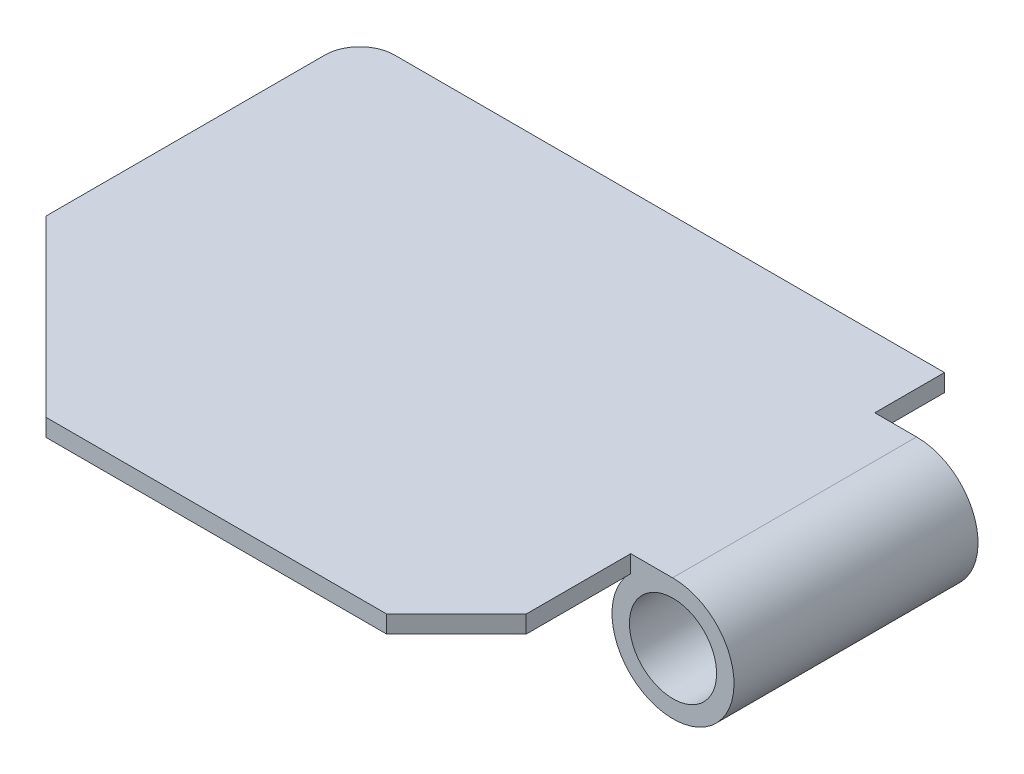
from build123d import *

# Parameters (mm, degrees)
BOSS_EXTRUDE1_DEPTH = 5
SKETCH3_R           = 17.5
SKETCH3_R_2         = 12.5
BOSS_EXTRUDE2_DEPTH = 70


with BuildPart() as part:
    # Sketch1 → Boss-Extrude1 (new body)
    with BuildSketch(Plane(origin=(0, 0, 0), x_dir=(1, 0, 0), z_dir=(0, 1, 0))):
        with BuildLine():
            Line((0, 0), (97.75, 0))
            Line((97.75, 0), (117.746979772, 19.996979772))
            Line((117.746979772, 19.996979772), (117.746979772, 49.996979772))
            Line((117.746979772, 49.996979772), (130.000479502, 49.996979772))
            Line((130.000479502, 49.996979772), (130.000479502, 119.996979772))
            Line((130.000479502, 119.996979772), (117.750479502, 119.996979772))
            Line((117.750479502, 119.996979772), (117.750479502, 139.999520498))
            Line((117.750479502, 139.999520498), (-39.999520498, 139.999520498))
            ThreePointArc((-39.999520498, 139.999520498), (-47.07058831, 137.07058831), (-49.999520498, 129.999520498))
            Line((-49.999520498, 129.999520498), (-49.999520498, 49.999520498))
            Line((-49.999520498, 49.999520498), (0, 0))
        make_face()
    extrude(amount=-BOSS_EXTRUDE1_DEPTH)

    # Sketch3 → Boss-Extrude2 (add)
    with BuildSketch(Plane(origin=(0, 0, -119.996979772), x_dir=(-1, 0, 0), z_dir=(0, 0, -1))):
        with Locations((-129.871326169, -17.499523405)):
            Circle(SKETCH3_R)
        with Locations((-129.871326169, -17.499523405)):
            Circle(SKETCH3_R_2, mode=Mode.SUBTRACT)
    extrude(amount=-BOSS_EXTRUDE2_DEPTH)


solid = part.part
